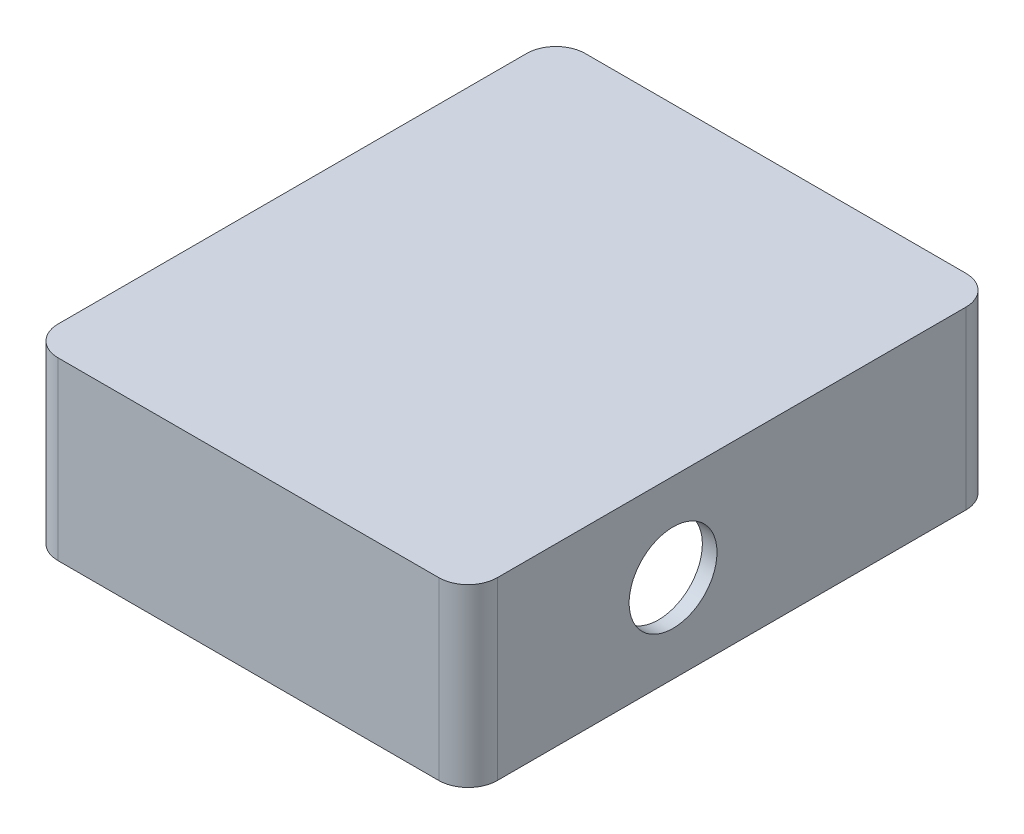
from build123d import *

# Parameters (mm, degrees)
BOSS_EXTRUDE1_DEPTH = 30
CUT_EXTRUDE3_DEPTH  = 28
SKETCH5_R           = 7.5
CUT_EXTRUDE5_DEPTH  = 4


with BuildPart() as part:
    # Sketch1 → Boss-Extrude1 (new body)
    with BuildSketch(Plane(origin=(0, 0, 0), x_dir=(1, 0, 0), z_dir=(0, 1, 0))):
        with BuildLine():
            Line((5, 0), (70, 0))
            ThreePointArc((70, 0), (73.535533906, 1.464466094), (75, 5))
            Line((75, 5), (75, 85))
            ThreePointArc((75, 85), (73.535533906, 88.535533906), (70, 90))
            Line((70, 90), (5, 90))
            ThreePointArc((5, 90), (1.464466094, 88.535533906), (0, 85))
            Line((0, 85), (0, 5))
            ThreePointArc((0, 5), (1.464466094, 1.464466094), (5, 0))
        make_face()
    extrude(amount=BOSS_EXTRUDE1_DEPTH)

    # Sketch3 → Cut-Extrude3 (cut)
    with BuildSketch(Plane(origin=(0, 0, 0), x_dir=(-1, 0, 0), z_dir=(0, -1, 0))):
        with BuildLine():
            Line((-7.5, 2.5), (-67.5, 2.5))
            ThreePointArc((-67.5, 2.5), (-71.035533906, 3.964466094), (-72.5, 7.5))
            Line((-72.5, 7.5), (-72.5, 82.5))
            ThreePointArc((-72.5, 82.5), (-71.035533906, 86.035533906), (-67.5, 87.5))
            Line((-67.5, 87.5), (-7.5, 87.5))
            ThreePointArc((-7.5, 87.5), (-3.964466094, 86.035533906), (-2.5, 82.5))
            Line((-2.5, 82.5), (-2.5, 7.5))
            ThreePointArc((-2.5, 7.5), (-3.964466094, 3.964466094), (-7.5, 2.5))
        make_face()
    extrude(amount=-CUT_EXTRUDE3_DEPTH, mode=Mode.SUBTRACT)

    # Sketch5 → Cut-Extrude5 (cut)
    with BuildSketch(Plane(origin=(75, 0, 0), x_dir=(0, 0, -1), z_dir=(1, 0, 0))):
        with Locations((35, 15)):
            Circle(SKETCH5_R)
    extrude(amount=-CUT_EXTRUDE5_DEPTH, mode=Mode.SUBTRACT)


solid = part.part
